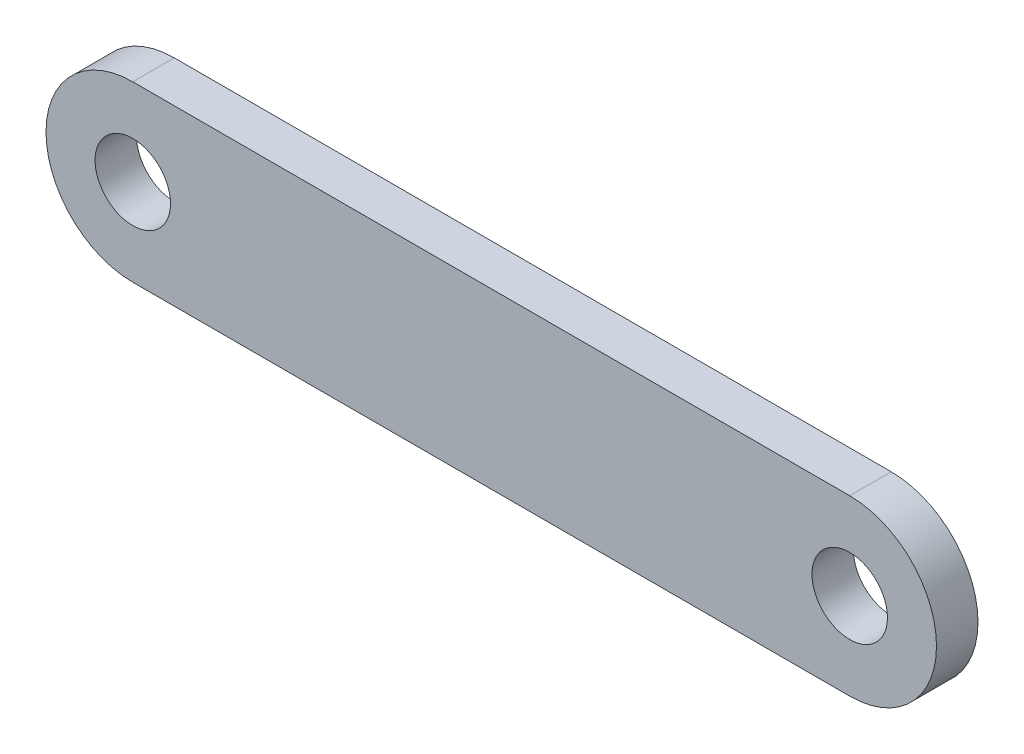
from build123d import *

# Parameters (mm, degrees)
SKETCH1_R     = 5
LINK_AB_DEPTH = 2.75


with BuildPart() as part:
    # Sketch1 → link_AB (new body, symmetric)
    with BuildSketch(Plane.XY):
        with BuildLine():
            Line((-47.5, 11.5), (47.5, 11.5))
            ThreePointArc((47.5, 11.5), (59, 0), (47.5, -11.5))
            Line((47.5, -11.5), (-47.5, -11.5))
            ThreePointArc((-47.5, -11.5), (-59, 0), (-47.5, 11.5))
        make_face()
        with Locations((-47.5, 0)):
            Circle(SKETCH1_R, mode=Mode.SUBTRACT)
        with Locations((47.5, 0)):
            Circle(SKETCH1_R, mode=Mode.SUBTRACT)
    extrude(amount=LINK_AB_DEPTH, both=True)


solid = part.part
